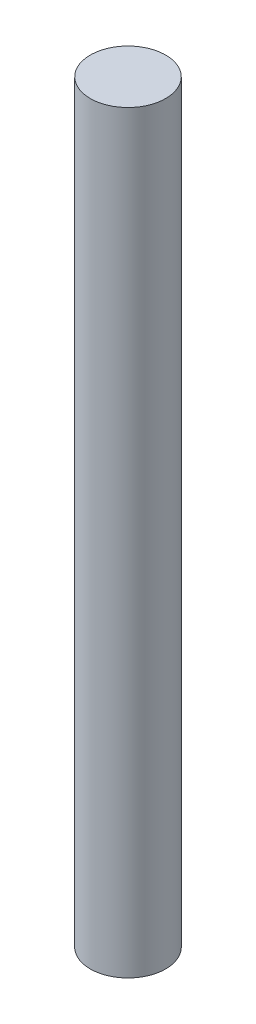
from build123d import *

# Parameters (mm, degrees)
SKETCH1_R           = 3.175
BOSS_EXTRUDE1_DEPTH = 31.75


with BuildPart() as part:
    # Sketch1 → Boss-Extrude1 (new body, symmetric)
    with BuildSketch(Plane(origin=(0, 0, 0), x_dir=(1, 0, 0), z_dir=(0, 1, 0))):
        Circle(SKETCH1_R)
    extrude(amount=BOSS_EXTRUDE1_DEPTH, both=True)


solid = part.part
